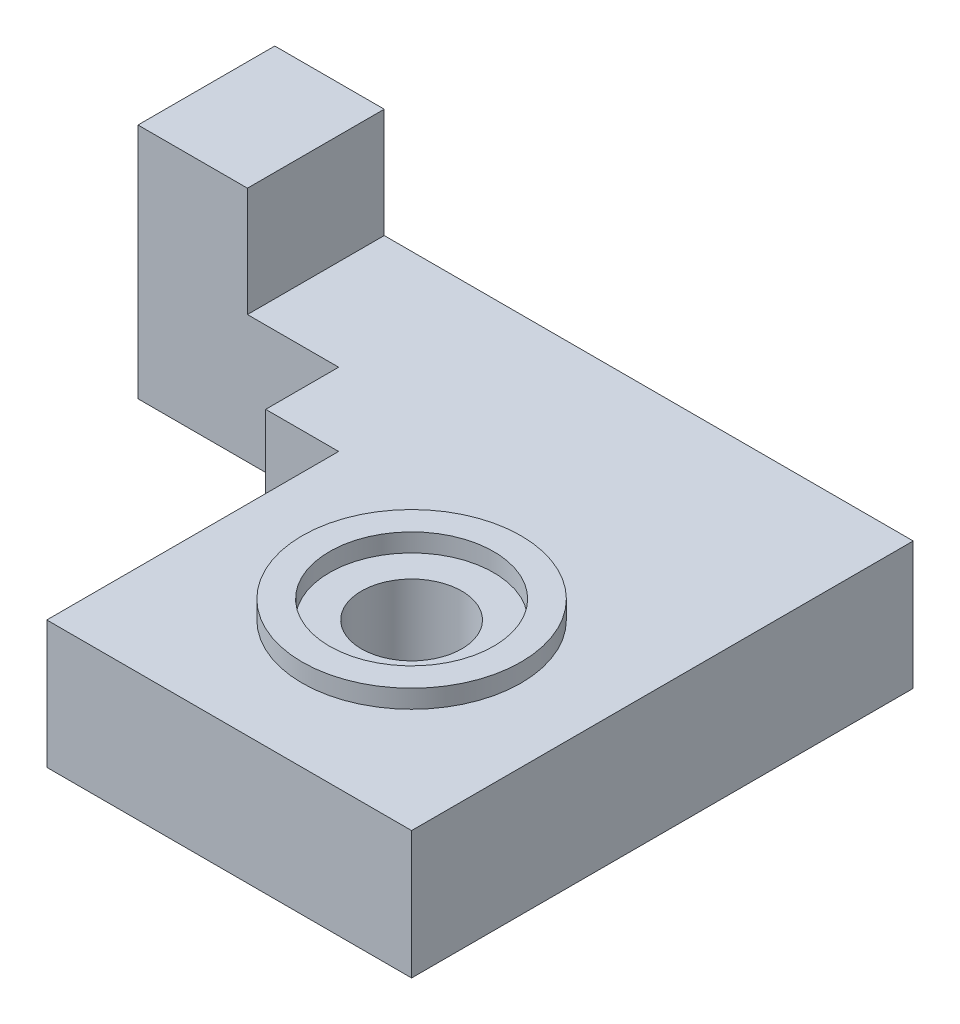
from build123d import *

# Parameters (mm, degrees)
SKETCH1_W                       = 15
SKETCH1_H                       = 7.5
SKETCH1_W_2                     = 20
SKETCH1_H_2                     = 27.5
BOSS_EXTRUDE1_DEPTH             = 7
SKETCH2_W                       = 6
SKETCH2_H                       = 7.5
BOSS_EXTRUDE2_DEPTH             = 6
SKETCH8_R                       = 6
BOSS_EXTRUDE4_DEPTH             = 1
SKETCH6_R                       = 1
CUT_EXTRUDE1_DEPTH              = 4
SKETCH7_W                       = 4
SKETCH7_H                       = 11
BOSS_EXTRUDE3_DEPTH             = 4
CBORE_FOR_M5_SBHCS2_D           = 5.5
CBORE_FOR_M5_SBHCS2_CBORE_D     = 9
CBORE_FOR_M5_SBHCS2_CBORE_DEPTH = 1
CHAMFER1_SIZE                   = 2


with BuildPart() as part:
    # Sketch1 → Boss-Extrude1 (new body)
    with BuildSketch(Plane(origin=(0, 0, 0), x_dir=(1, 0, 0), z_dir=(0, 1, 0))):
        with Locations((-7.5, 23.75)):
            Rectangle(SKETCH1_W, SKETCH1_H)
        with Locations((10, 13.75)):
            Rectangle(SKETCH1_W_2, SKETCH1_H_2)
    extrude(amount=BOSS_EXTRUDE1_DEPTH)

    # Sketch2 → Boss-Extrude2 (add)
    with BuildSketch(Plane(origin=(0, 7, 0), x_dir=(1, 0, 0), z_dir=(0, 1, 0))):
        with Locations((-12, 23.75)):
            Rectangle(SKETCH2_W, SKETCH2_H)
    extrude(amount=BOSS_EXTRUDE2_DEPTH)

    # Sketch8 → Boss-Extrude4 (add)
    with BuildSketch(Plane(origin=(0, 7, 0), x_dir=(1, 0, 0), z_dir=(0, 1, 0))):
        with Locations((10, 10)):
            Circle(SKETCH8_R)
    extrude(amount=BOSS_EXTRUDE4_DEPTH)

    # Sketch6 → Cut-Extrude1 (cut)
    with BuildSketch(Plane.ZY.offset(15)):
        with Locations((-25.5, 9.75)):
            Circle(SKETCH6_R)
        with Locations((-25.5, 3.25)):
            Circle(SKETCH6_R)
    extrude(amount=-CUT_EXTRUDE1_DEPTH, mode=Mode.SUBTRACT)

    # Sketch7 → Boss-Extrude3 (add)
    with BuildSketch(Plane.XY.offset(-20)):
        with Locations((-2, 1.5)):
            Rectangle(SKETCH7_W, SKETCH7_H)
    extrude(amount=BOSS_EXTRUDE3_DEPTH)

    # CBORE for M5 SBHCS2 (through all)
    with Locations(Plane(origin=(0, 8, 0), x_dir=(1, 0, 0), z_dir=(0, 1, 0))):
        with Locations((10, 10)):
            CounterBoreHole(CBORE_FOR_M5_SBHCS2_D / 2, CBORE_FOR_M5_SBHCS2_CBORE_D / 2, CBORE_FOR_M5_SBHCS2_CBORE_DEPTH)

    # Chamfer1
    chamfer1_edges = [part.edges().sort_by_distance(p)[0] for p in [
        (-4, -4, -18),
    ]]
    chamfer(chamfer1_edges, length=CHAMFER1_SIZE)


solid = part.part
